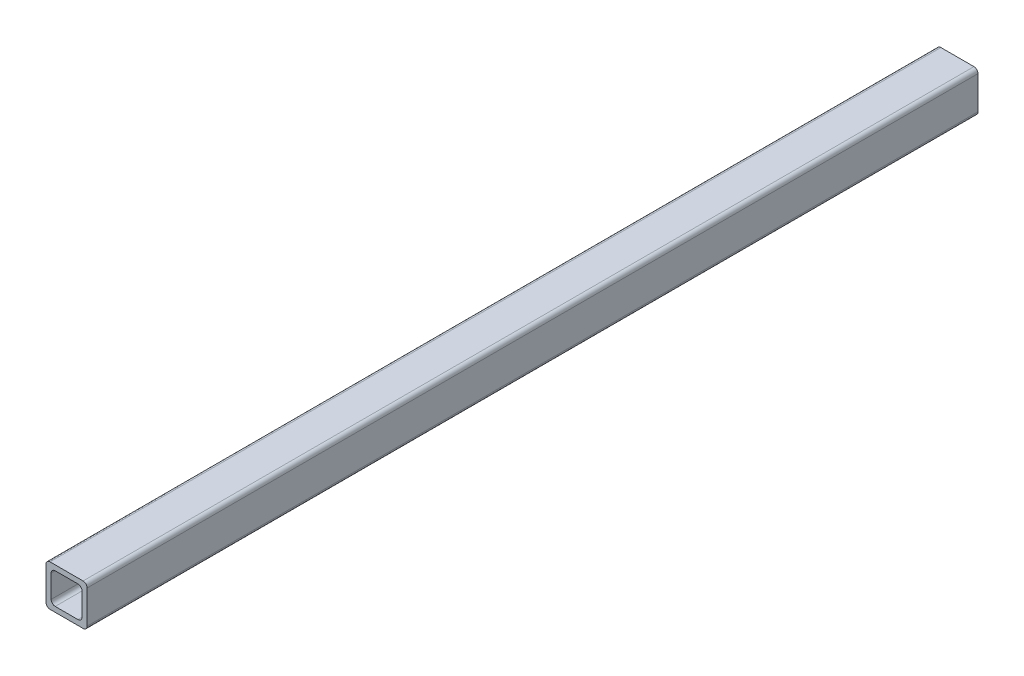
from build123d import *

# Parameters (mm, degrees)
SALIENTE_EXTRUIR1_DEPTH = 550


with BuildPart() as part:
    # Croquis1 → Saliente-Extruir1 (new body)
    with BuildSketch(Plane.XY):
        with BuildLine():
            Line((-10.2, -12.7), (10.2, -12.7))
            ThreePointArc((10.2, -12.7), (11.967766953, -11.967766953), (12.7, -10.2))
            Line((12.7, -10.2), (12.7, 10.2))
            ThreePointArc((12.7, 10.2), (11.967766953, 11.967766953), (10.2, 12.7))
            Line((10.2, 12.7), (-10.2, 12.7))
            ThreePointArc((-10.2, 12.7), (-11.967766953, 11.967766953), (-12.7, 10.2))
            Line((-12.7, 10.2), (-12.7, -10.2))
            ThreePointArc((-12.7, -10.2), (-11.967766953, -11.967766953), (-10.2, -12.7))
        make_face()
        with BuildLine():
            Line((-7.025, -9.525), (7.025, -9.525))
            ThreePointArc((7.025, -9.525), (8.792766953, -8.792766953), (9.525, -7.025))
            Line((9.525, -7.025), (9.525, 7.025))
            ThreePointArc((9.525, 7.025), (8.792766953, 8.792766953), (7.025, 9.525))
            Line((7.025, 9.525), (-7.025, 9.525))
            ThreePointArc((-7.025, 9.525), (-8.792766953, 8.792766953), (-9.525, 7.025))
            Line((-9.525, 7.025), (-9.525, -7.025))
            ThreePointArc((-9.525, -7.025), (-8.792766953, -8.792766953), (-7.025, -9.525))
        make_face(mode=Mode.SUBTRACT)
    extrude(amount=SALIENTE_EXTRUIR1_DEPTH)


solid = part.part
